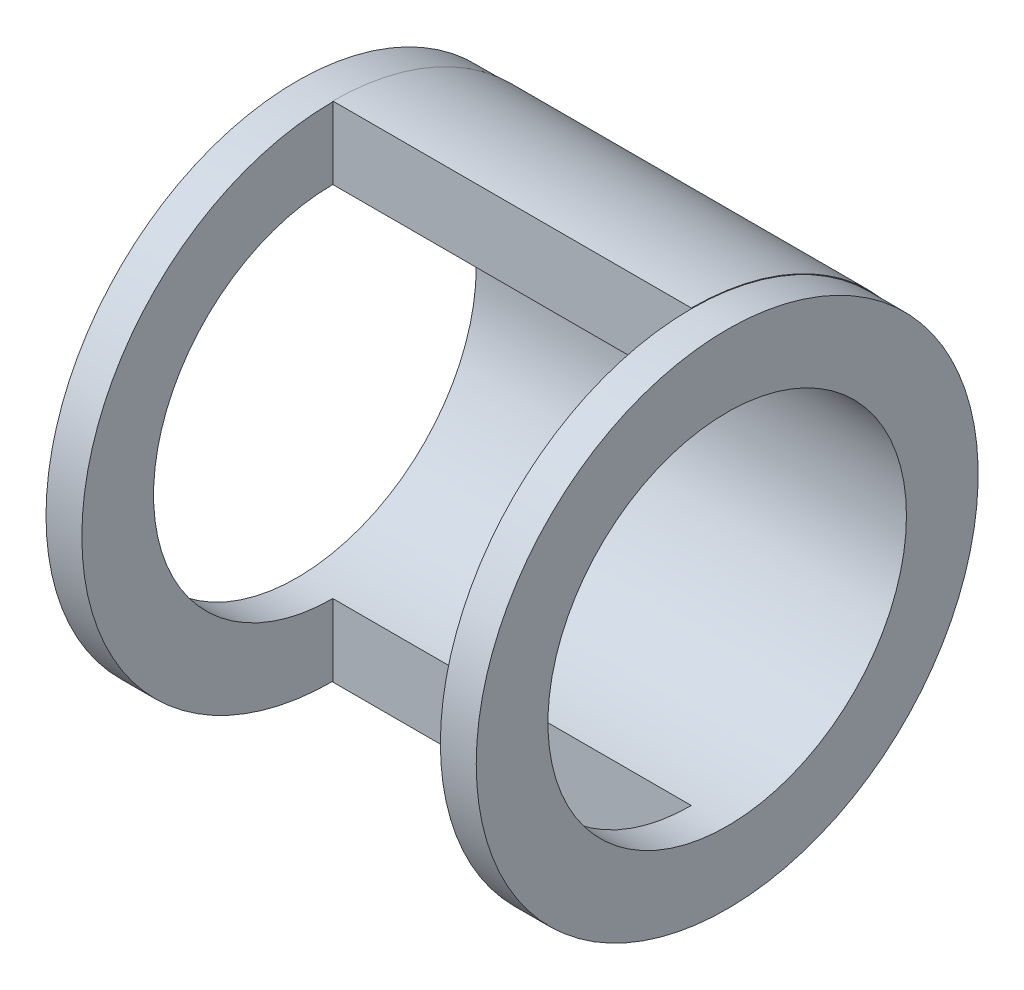
from build123d import *

# Parameters (mm, degrees)
ESQUISSE1_W                  = 10
ESQUISSE1_H                  = 70
ESQUISSE1_4_W                = 10
ESQUISSE1_4_H                = 70
ESQUISSE14_W                 = 100
ESQUISSE14_H                 = 70.182088946
R_VOLUTION5_ANGLE            = 180
ESQUISSE15_R                 = 50
ENL_V_MAT_EXTRU_1_DEPTH      = 111
ENL_V_MAT_EXTRU_1_DEPTH_BACK = 11


with BuildPart() as part:
    # Esquisse1 → R_vol.-Mince2 (revolve)
    with BuildSketch(Plane.XY):
        with Locations((-45, 35)):
            Rectangle(ESQUISSE1_W, ESQUISSE1_H)
    revolve(axis=Axis((-50, 0, 0), (1, 0, 0)))



with BuildPart() as body_2:
    # Esquisse1_4 → R_vol.-Mince3 (revolve)
    with BuildSketch(Plane.XY):
        with Locations((65, 35)):
            Rectangle(ESQUISSE1_4_W, ESQUISSE1_4_H)
    revolve(axis=Axis((-50, 0, 0), (1, 0, 0)))


with BuildPart() as part_1:
    add(part.part)

    add(body_2.part)  # R_volution5 merges body 2
    # Esquisse14 → R_volution5 (revolve)
    with BuildSketch(Plane.XY):
        with Locations((10, 35.091044473)):
            Rectangle(ESQUISSE14_W, ESQUISSE14_H)
    revolve(axis=Axis((60, 0, 0), (-1, 0, 0)), revolution_arc=R_VOLUTION5_ANGLE)

    # Esquisse15 → Enl_v. mat.-Extru.1 (cut, two sides)
    with BuildSketch(Plane(origin=(-40, 0, 0), x_dir=(0, 0, -1), z_dir=(1, 0, 0))) as enl_v_mat_extru_1_sk:
        Circle(ESQUISSE15_R)
    extrude(amount=ENL_V_MAT_EXTRU_1_DEPTH, mode=Mode.SUBTRACT)
    extrude(enl_v_mat_extru_1_sk.sketch, amount=-ENL_V_MAT_EXTRU_1_DEPTH_BACK, mode=Mode.SUBTRACT)


solid = part_1.part
